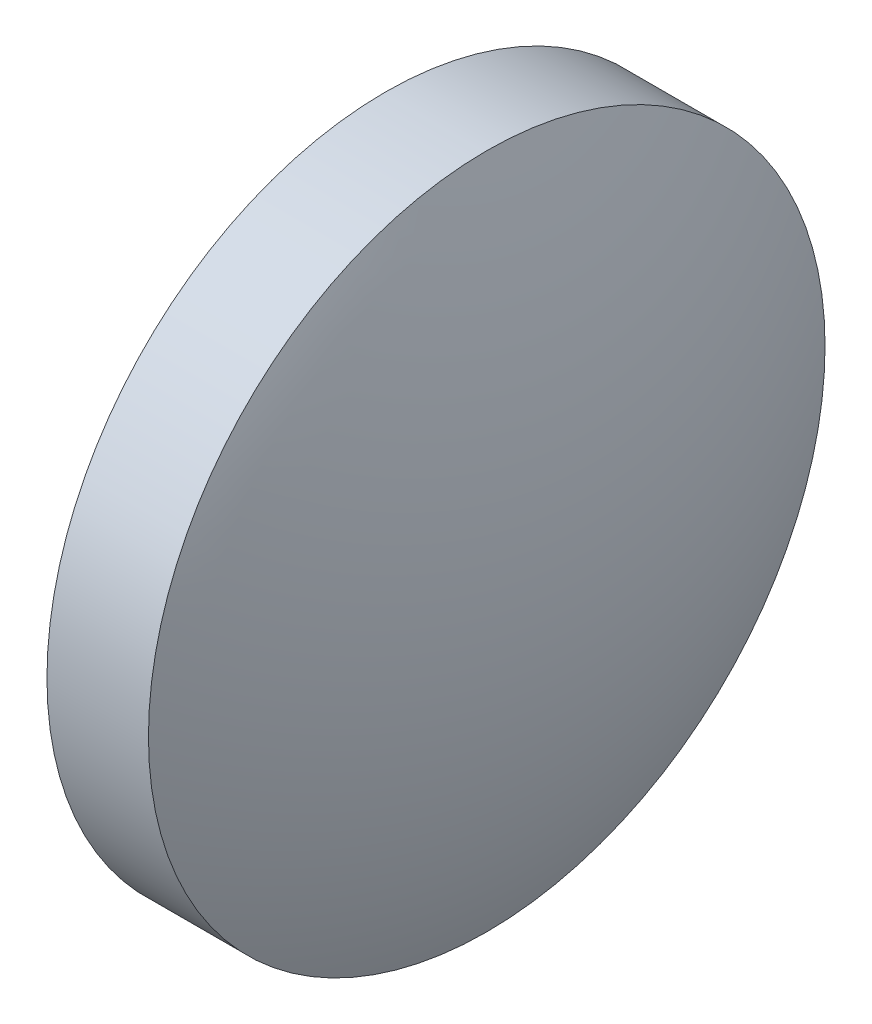
from build123d import *

# Parameters (mm, degrees)
SKETCH_1_ONE_SIDE_W = 10.5
SKETCH_1_ONE_SIDE_H = 35


with BuildPart() as part:
    # 草图1 one side → 旋转1 (revolve)
    with BuildSketch(Plane.XY, mode=Mode.PRIVATE) as revolve_1_sk:
        with Locations((238.270612765, 151.481413843)):
            Rectangle(SKETCH_1_ONE_SIDE_W, SKETCH_1_ONE_SIDE_H)
        with BuildLine():
            Line((225.569425289, 133.981413843), (233.020612765, 133.981413843))
            Line((233.020612765, 133.981413843), (233.020612765, 168.981413843))
            ThreePointArc((233.020612765, 168.981413843), (227.452863689, 151.873592266), (225.569425289, 133.981413843))
        make_face()
        with BuildLine():
            Line((243.520612765, 133.981413843), (250.97180024, 133.981413843))
            ThreePointArc((250.97180024, 133.981413843), (249.088361841, 151.873592266), (243.520612765, 168.981413843))
            Line((243.520612765, 168.981413843), (243.520612765, 133.981413843))
        make_face()
    revolve(revolve_1_sk.sketch.rotate(Axis((222.896606648, 133.981413843, 0), (1, 0, 0)), 90), axis=Axis((222.896606648, 133.981413843, 0), (1, 0, 0)))  # turned: the seam where the file's is


solid = part.part
